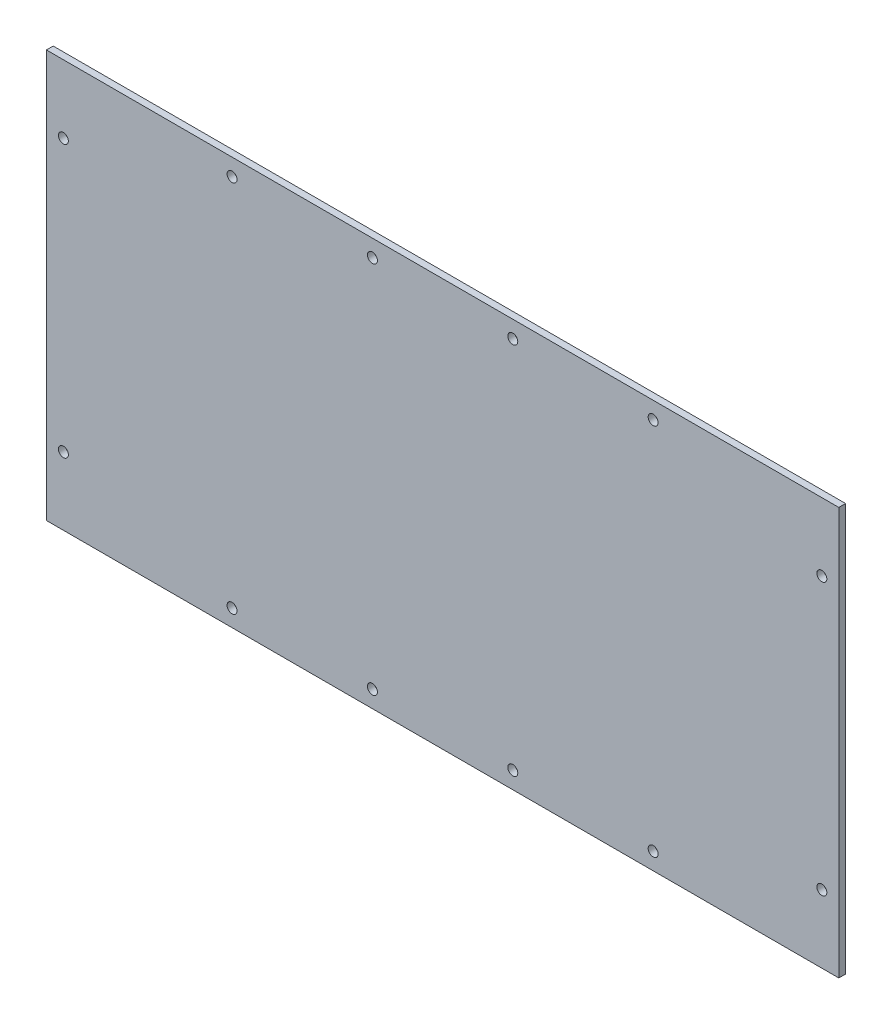
from build123d import *

# Parameters (mm, degrees)
SKETCH_1_W          = 350
SKETCH_1_H          = 180
EXTRUDE_1_DEPTH     = 3
CUT_EXTRUDE_1_DEPTH = 140
SKETCH_3_R          = 2.2
CUT_EXTRUDE_2_DEPTH = 310
SKETCH_4_R          = 2.2
CUT_EXTRUDE_3_DEPTH = 310


with BuildPart() as part:
    # ｽｹｯﾁ1 → ﾎﾞｽ - 押し出し1 (new body)
    with BuildSketch(Plane.XY):
        Rectangle(SKETCH_1_W, SKETCH_1_H)
    extrude(amount=EXTRUDE_1_DEPTH)

    # ｽｹｯﾁ2 → ｶｯﾄ - 押し出し1 (cut)
    with BuildSketch(Plane.XY.offset(3)):
        with BuildLine():
            ThreePointArc((169.7, 60), (169.055634919, 61.555634919), (167.5, 62.2))
            Line((167.5, 62.2), (167.5, 60))
            Line((167.5, 60), (169.7, 60))
        make_face()
        with BuildLine():
            Line((167.5, 60), (167.5, 62.2))
            ThreePointArc((167.5, 62.2), (165.944365081, 58.444365081), (169.7, 60))
            Line((169.7, 60), (167.5, 60))
        make_face()
        with BuildLine():
            ThreePointArc((169.7, -60), (165.944365081, -58.444365081), (167.5, -62.2))
            Line((167.5, -62.2), (167.5, -60))
            Line((167.5, -60), (169.7, -60))
        make_face()
        with BuildLine():
            Line((167.5, -60), (167.5, -62.2))
            ThreePointArc((167.5, -62.2), (169.055634919, -61.555634919), (169.7, -60))
            Line((169.7, -60), (167.5, -60))
        make_face()
        with BuildLine():
            ThreePointArc((-165.3, 60), (-165.944365081, 61.555634919), (-167.5, 62.2))
            Line((-167.5, 62.2), (-167.5, 60))
            Line((-167.5, 60), (-169.7, 60))
            ThreePointArc((-169.7, 60), (-167.5, 57.8), (-165.3, 60))
        make_face()
        with BuildLine():
            Line((-167.5, 60), (-167.5, 62.2))
            ThreePointArc((-167.5, 62.2), (-169.055634919, 61.555634919), (-169.7, 60))
            Line((-169.7, 60), (-167.5, 60))
        make_face()
        with BuildLine():
            ThreePointArc((-169.7, -60), (-169.055634919, -61.555634919), (-167.5, -62.2))
            Line((-167.5, -62.2), (-167.5, -60))
            Line((-167.5, -60), (-169.7, -60))
        make_face()
        with BuildLine():
            Line((-167.5, -60), (-167.5, -62.2))
            ThreePointArc((-167.5, -62.2), (-165.944365081, -61.555634919), (-165.3, -60))
            ThreePointArc((-165.3, -60), (-167.5, -57.8), (-169.7, -60))
            Line((-169.7, -60), (-167.5, -60))
        make_face()
    extrude(amount=-CUT_EXTRUDE_1_DEPTH, mode=Mode.SUBTRACT)

    # ｽｹｯﾁ3 → ｶｯﾄ - 押し出し2 (cut)
    with BuildSketch(Plane.XY.offset(3)):
        with Locations((93, 82.5)):
            Circle(SKETCH_3_R)
        with Locations((31, 82.5)):
            Circle(SKETCH_3_R)
        with Locations((-31, 82.5)):
            Circle(SKETCH_3_R)
        with Locations((-93, 82.5)):
            Circle(SKETCH_3_R)
    extrude(amount=-CUT_EXTRUDE_2_DEPTH, mode=Mode.SUBTRACT)

    # ｽｹｯﾁ4 → ｶｯﾄ - 押し出し3 (cut)
    with BuildSketch(Plane.XY.offset(3)):
        with Locations((93, -82.5)):
            Circle(SKETCH_4_R)
        with Locations((31, -82.5)):
            Circle(SKETCH_4_R)
        with Locations((-31, -82.5)):
            Circle(SKETCH_4_R)
        with Locations((-93, -82.5)):
            Circle(SKETCH_4_R)
    extrude(amount=-CUT_EXTRUDE_3_DEPTH, mode=Mode.SUBTRACT)


solid = part.part
